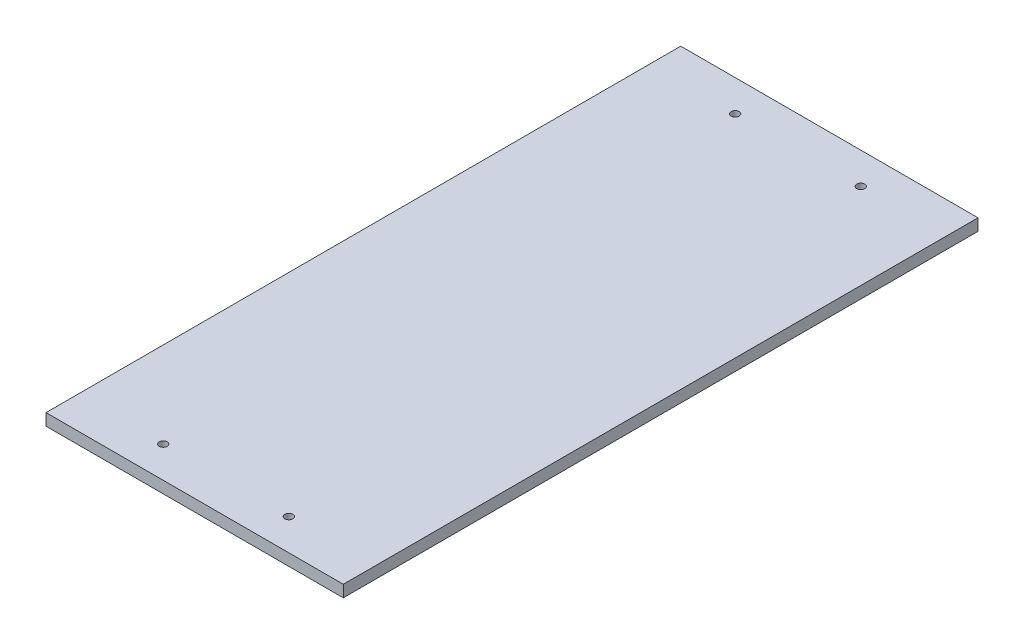
from build123d import *

# Parameters (mm, degrees)
SKETCH3_W           = 304.8
SKETCH3_H           = 609.6
BOSS_EXTRUDE1_DEPTH = 9.525
CUT_EXTRUDE1_DEPTH  = 15.24
SKETCH9_R           = 3.2258
CUT_EXTRUDE3_DEPTH  = 10.525


with BuildPart() as part:
    # Sketch3 → Boss-Extrude1 (new body)
    with BuildSketch(Plane(origin=(0, 0, 0), x_dir=(1, 0, 0), z_dir=(0, 1, 0))):
        Rectangle(SKETCH3_W, SKETCH3_H)
    extrude(amount=-BOSS_EXTRUDE1_DEPTH)

    # Sketch4 → Cut-Extrude1 (cut)
    with BuildSketch(Plane(origin=(0, 0, 0), x_dir=(1, 0, 0), z_dir=(0, 1, 0))):
        Polygon((-152.4, 304.8), (152.4, 304.8), (152.4, 208.661), (152.4, -304.8), (120.245, -304.8), (120.245, 208.661), (-120.245, 208.661), (-120.245, -304.8), (-152.4, -304.8), (-152.4, 208.661), align=None)
    extrude(amount=-CUT_EXTRUDE1_DEPTH, mode=Mode.SUBTRACT)

    # Sketch9 → Cut-Extrude3 (cut, through all)
    with BuildSketch(Plane(origin=(0, -9.525, 0), x_dir=(-1, 0, 0), z_dir=(0, -1, 0))):
        with Locations((-50.8, 183.261)):
            Circle(SKETCH9_R)
        with Locations((50.8, 183.261)):
            Circle(SKETCH9_R)
        with Locations((50.8, -279.4)):
            Circle(SKETCH9_R)
        with Locations((-50.8, -279.4)):
            Circle(SKETCH9_R)
    extrude(amount=-CUT_EXTRUDE3_DEPTH, mode=Mode.SUBTRACT)


solid = part.part
